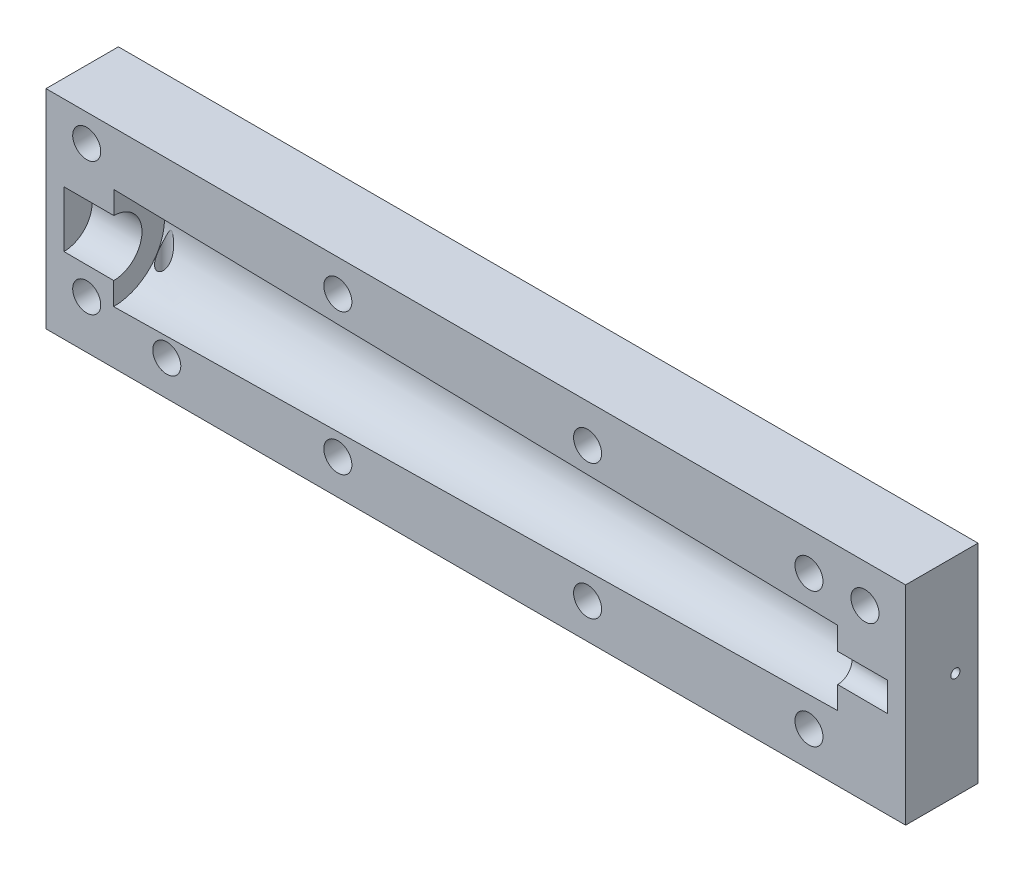
from build123d import *

# Parameters (mm, degrees)
SKIZZE2_W                                  = 120
SKIZZE2_H                                  = 40
AUFSATZ_LINEAR_AUSTRAGEN1_DEPTH            = 30
SKIZZE80_R                                 = 0.5
SCHNITT_LINEAR_AUSTRAGEN34_DEPTH           = 21.05
SCHNITT_LINEAR_START                       = -9
SKIZZE81_R                                 = 0.5
SCHNITT_LINEAR_AUSTRAGEN36_DEPTH           = 5
SKIZZE89_R                                 = 0.75
SCHNITT_LINEAR_AUSTRAGEN37_DEPTH           = 19
SKIZZE89_3_R                               = 2.1
SKIZZE89_3_R_2                             = 0.75
SCHNITT_LINEAR_AUSTRAGEN38_DEPTH           = 12
FASE1_SIZE                                 = 1.3
F_3_1_3_1_DURCHMESSER_BOHRUNG1_D           = 3.1
F_3_1_3_1_DURCHMESSER_BOHRUNG1_CSINK_D     = 3.15
F_3_1_3_1_DURCHMESSER_BOHRUNG1_CSINK_ANGLE = 90
SKIZZE83_W                                 = 8.5
SKIZZE83_H                                 = 23
SKIZZE83_W_2                               = 7
SCHNITT_LINEAR_AUSTRAGEN39_DEPTH           = 135
SKIZZE93_W                                 = 12.5
SKIZZE93_H                                 = 14.5
SCHNITT_LINEAR_AUSTRAGEN40_DEPTH           = 135
ABSPALTEN1_SURFACE_1_BACK                  = 99.814
ABSPALTEN1_SURFACE_1_DEPTH                 = 199.628


with BuildPart() as part:
    # Skizze2 → Aufsatz-Linear austragen1 (new body)
    with BuildSketch(Plane.XY):
        with Locations((60, 20)):
            Rectangle(SKIZZE2_W, SKIZZE2_H)
    extrude(amount=AUFSATZ_LINEAR_AUSTRAGEN1_DEPTH)

    # Skizze80 → Schnitt-Linear austragen34 (cut)
    with BuildSketch(Plane(origin=(120, 0, 0), x_dir=(0, 0, -1), z_dir=(1, 0, 0))):
        with Locations((-20.502569313, 19.779069372)):
            Circle(SKIZZE80_R)
    schnitt_linear_austragen34 = extrude(amount=-SCHNITT_LINEAR_AUSTRAGEN34_DEPTH, mode=Mode.SUBTRACT)

    # Skizze81 → Schnitt-Linear austragen36 (cut)
    with BuildSketch(Plane.XY.offset(30).offset(SCHNITT_LINEAR_START)):
        with Locations((99, 20)):
            Circle(SKIZZE81_R)
    schnitt_linear_austragen36 = extrude(amount=-SCHNITT_LINEAR_AUSTRAGEN36_DEPTH, mode=Mode.SUBTRACT)

    # Spiegeln4: Schnitt-Linear austragen34, Schnitt-Linear austragen36 across plane
    add(schnitt_linear_austragen34.mirror(Plane.XY.offset(15)), mode=Mode.SUBTRACT)
    add(schnitt_linear_austragen36.mirror(Plane.XY.offset(15)), mode=Mode.SUBTRACT)

    # Skizze89 → Schnitt-Linear austragen37 (cut)
    with BuildSketch(Plane.XZ):
        with Locations(Location((20.75, 10.195, 0), (0, 0, 270))):
            Circle(SKIZZE89_R)
    extrude(amount=-SCHNITT_LINEAR_AUSTRAGEN37_DEPTH, mode=Mode.SUBTRACT)

    # Skizze89_3 → Schnitt-Linear austragen38 (cut)
    with BuildSketch(Plane.XZ):
        with Locations(Location((20.75, 10.195, 0), (0, 0, 270))):
            Circle(SKIZZE89_3_R)
        with Locations(Location((20.75, 10.195, 0), (0, 0, 270))):
            Circle(SKIZZE89_3_R_2, mode=Mode.SUBTRACT)
    extrude(amount=-SCHNITT_LINEAR_AUSTRAGEN38_DEPTH, mode=Mode.SUBTRACT)

    # Fase1
    fase1_edges = [part.edges().sort_by_distance(p)[0] for p in [
        (20.75, 12, 10.945),
    ]]
    chamfer(fase1_edges, length=FASE1_SIZE)

    # 3.1 _3.1_ Durchmesser Bohrung1 (through all)
    with Locations(Plane(origin=(0, 0, 0), x_dir=(-1, 0, 0), z_dir=(0, 0, -1))):
        with Locations((-17, 28), (-44.752782077, 27.472603229), (-72.354196867, 26.76756786), (-96.819713549, 26.76756786), (-103.008357344, 26.76756786), (-17, 13.319343937), (-25.846153065, 11.883487847), (-44.752782077, 11.883487847), (-72.354196867, 11.883487847), (-96.819713549, 11.883487847)):
            CounterSinkHole(F_3_1_3_1_DURCHMESSER_BOHRUNG1_D / 2, F_3_1_3_1_DURCHMESSER_BOHRUNG1_CSINK_D / 2, counter_sink_angle=F_3_1_3_1_DURCHMESSER_BOHRUNG1_CSINK_ANGLE)

    # Skizze83 → Schnitt-Linear austragen39 (cut)
    with BuildSketch(Plane.ZY):
        with Locations((25.75, 19.5)):
            Rectangle(SKIZZE83_W, SKIZZE83_H)
        Polygon((30, 0), (30, 8), (21.5, 8), (7, 8), (0, 8), (0, 0), align=None)
        with Locations((3.5, 19.5)):
            Rectangle(SKIZZE83_W_2, SKIZZE83_H)
        Polygon((21.5, 31), (30, 31), (30, 40), (0, 40), (0, 31), (7, 31), align=None)
    extrude(amount=-SCHNITT_LINEAR_AUSTRAGEN39_DEPTH, mode=Mode.SUBTRACT)

    # Skizze93 → Schnitt-Linear austragen40 (cut)
    with BuildSketch(Plane(origin=(0, 31, 0), x_dir=(1, 0, 0), z_dir=(0, 1, 0))):
        with Locations((113.75, -14.25)):
            Rectangle(SKIZZE93_W, SKIZZE93_H)
        with Locations((6.25, -14.25)):
            Rectangle(SKIZZE93_W, SKIZZE93_H)
    extrude(amount=-SCHNITT_LINEAR_AUSTRAGEN40_DEPTH, mode=Mode.SUBTRACT)

    # Skizze99 → Schnitt-Rotation2 (revolve, cut)
    with BuildSketch(Plane.XY.offset(15), mode=Mode.PRIVATE) as schnitt_rotation2_sk:
        Polygon((14.5, 19.495348829), (14.5, 22.595348829), (20, 22.595348829), (20, 25.095348829), (100, 23.383720543), (100, 20.883720543), (105.5, 20.883720543), (105.5, 19.283720543), align=None)
    revolve(schnitt_rotation2_sk.sketch.rotate(Axis((12.5, 19.5, 15), (0.9999972958368729, -0.0023255792701378343, 0)), 180), axis=Axis((12.5, 19.5, 15), (0.9999972958368729, -0.0023255792701378343, 0)), mode=Mode.SUBTRACT)

    # Abspalten1: cut with a surface, the side it looks to stays
    # Abspalten1 surface: a surface, the sketch's curves swept straight by 199.628 mm
    with BuildLine(Plane(origin=(107.5, 0, 0), x_dir=(0, 0, -1), z_dir=(1, 0, 0)).offset(-ABSPALTEN1_SURFACE_1_BACK), mode=Mode.PRIVATE) as abspalten1_surface_1_path:
        Line((-15, 31), (-15, 8))
    abspalten1_surface_1 = Shell.extrude(abspalten1_surface_1_path.wire(), (1 * ABSPALTEN1_SURFACE_1_DEPTH, 0 * ABSPALTEN1_SURFACE_1_DEPTH, 0 * ABSPALTEN1_SURFACE_1_DEPTH))
    split(bisect_by=abspalten1_surface_1, keep=Keep.TOP)


solid = part.part
